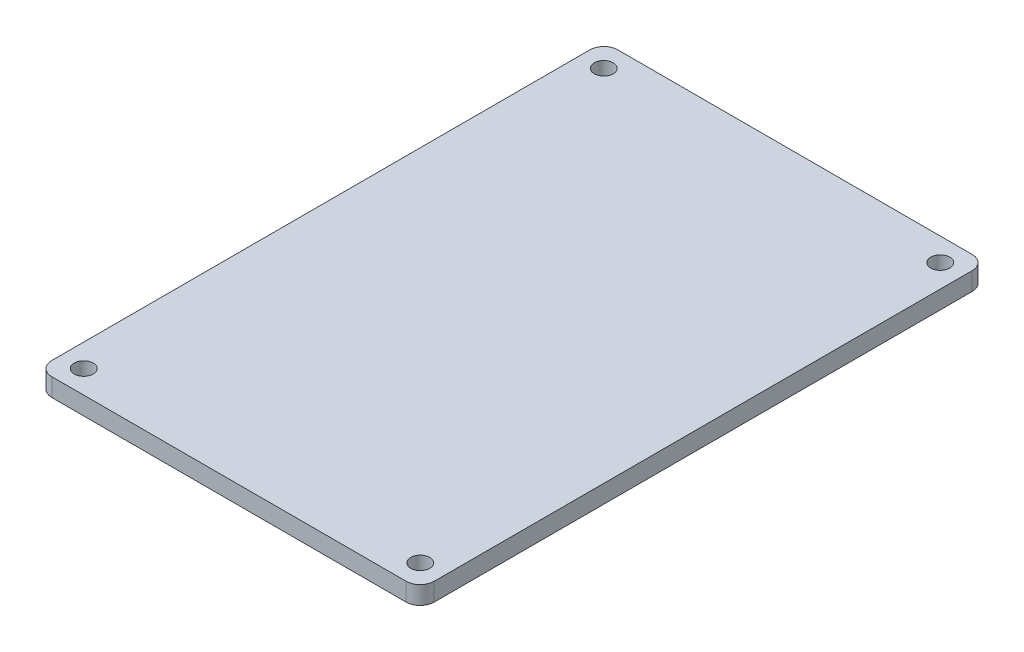
from build123d import *

# Parameters (mm, degrees)
BOSS_EXTRUDE1_DEPTH   = 3
F_1_0MM_DOWEL_HOLE1_D = 3.16


with BuildPart() as part:
    # Sketch1 → Boss-Extrude1 (new body)
    with BuildSketch(Plane(origin=(0, 0, 0), x_dir=(1, 0, 0), z_dir=(0, 1, 0))):
        with BuildLine():
            Line((-29.43, -47), (29.43, -47))
            ThreePointArc((29.43, -47), (31.070487732, -46.320487732), (31.75, -44.68))
            Line((31.75, -44.68), (31.75, 44.68))
            ThreePointArc((31.75, 44.68), (31.070487732, 46.320487732), (29.43, 47))
            Line((29.43, 47), (-29.43, 47))
            ThreePointArc((-29.43, 47), (-31.070487732, 46.320487732), (-31.75, 44.68))
            Line((-31.75, 44.68), (-31.75, -44.68))
            ThreePointArc((-31.75, -44.68), (-31.070487732, -46.320487732), (-29.43, -47))
        make_face()
    extrude(amount=BOSS_EXTRUDE1_DEPTH)

    # Ø1.0mm Dowel Hole1 (through all)
    with Locations(Plane(origin=(0, 3, 0), x_dir=(1, 0, 0), z_dir=(0, 1, 0))):
        with Locations((27.94, 43.18), (-27.94, 43.18), (-27.94, -43.18), (27.94, -43.18)):
            Hole(F_1_0MM_DOWEL_HOLE1_D / 2)


solid = part.part
